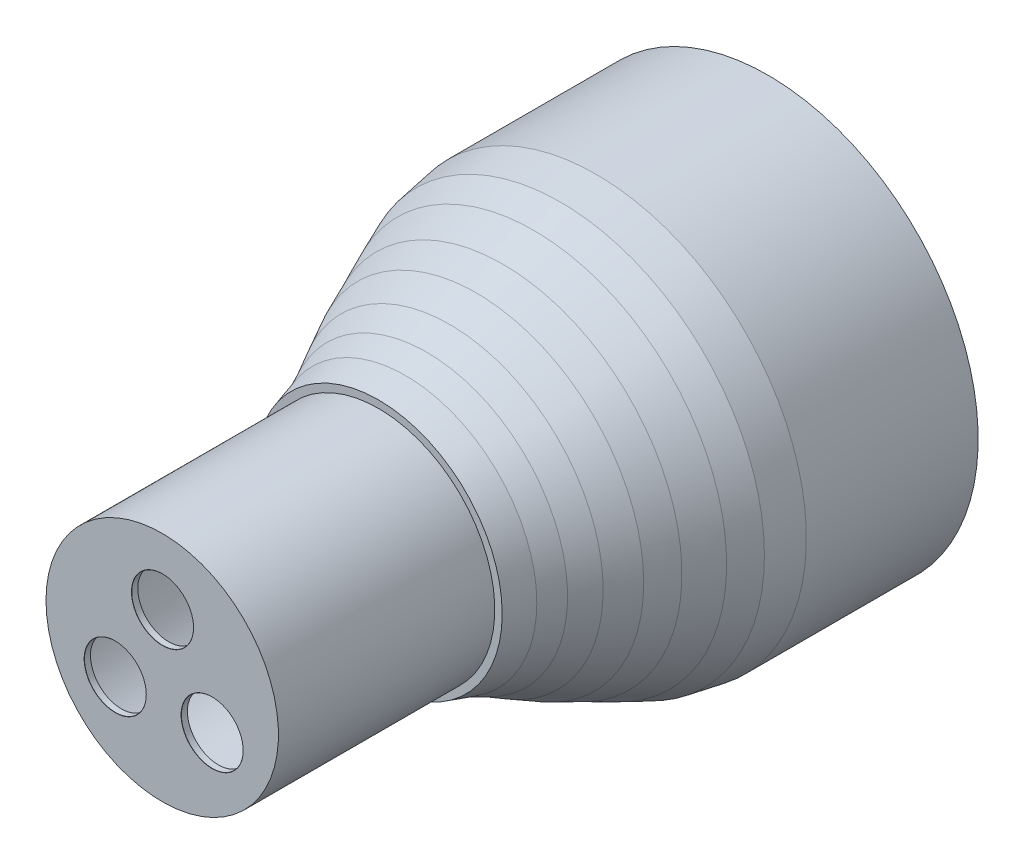
from build123d import *

# Parameters (mm, degrees)
F_10_0MM_DOWEL_HOLE1_D           = 10
F_10_0MM_DOWEL_HOLE1_CSINK_D     = 10.05
F_10_0MM_DOWEL_HOLE1_CSINK_ANGLE = 90


with BuildPart() as part:
    # ff → Revolve1 (revolve)
    with BuildSketch(Plane(origin=(0, 0, 0), x_dir=(1, 0, 0), z_dir=(0, 1, 0))):
        Polygon((-27.469034289, 50), (-28.669034289, 50), (-29.932925511, 54.335656855), (-31.468331613, 57.777529323), (-33.489527061, 61.506224497), (-35.752379109, 65.81164745), (-37.618887017, 70.122472229), (-39.86237248, 75.117178167), (-41.669034289, 79.422637332), (-42.669034289, 85.208855182), (-42.669034289, 90.333303824), (-42.669034289, 93), (-42.669034289, 113), (-41.669034289, 113), (-41.669034289, 93), (-39.371495413, 77.8398126), (-34.076931722, 65.81164745), (-29.932925511, 59.326371933), (-27.094890318, 53.934105067), (-26.469034289, 50), (-26.469034289, 16), (-8.669034289, 16), (-8.669034289, 15), (-27.469034289, 15), align=None)
    revolve(axis=Axis((-8.669034289, 0, -16), (0, 0, 1)))

    # Ø10.0mm Dowel Hole1 (through all)
    with Locations(Plane.XY.offset(-15)):
        with Locations((-8.62181152, 8.122316285), (-16.271900114, -5.100059063), (-0.593940773, -5.100059063)):
            CounterSinkHole(F_10_0MM_DOWEL_HOLE1_D / 2, F_10_0MM_DOWEL_HOLE1_CSINK_D / 2, counter_sink_angle=F_10_0MM_DOWEL_HOLE1_CSINK_ANGLE)


solid = part.part
